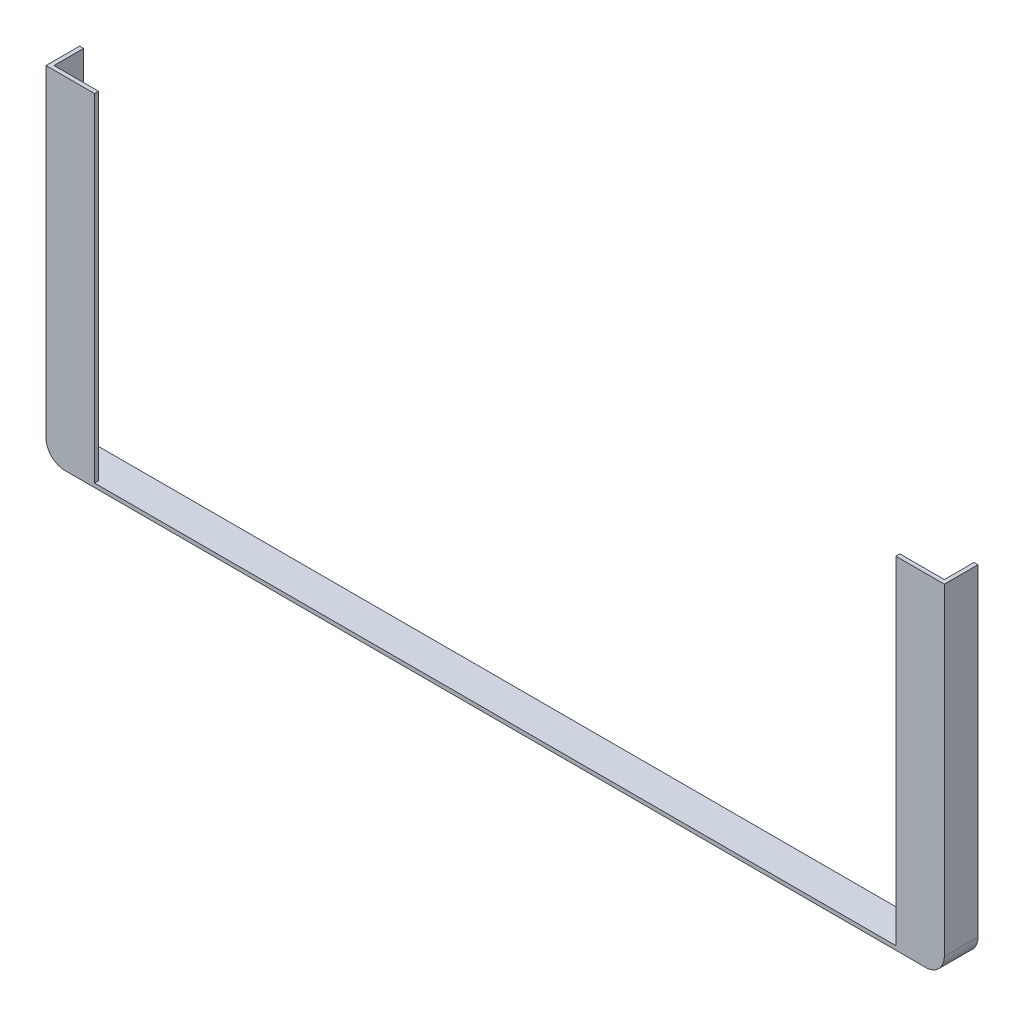
from build123d import *

# Parameters (mm, degrees)
SIDE_DEPTH     = 25.4
PANEL_DEPTH    = 3.4163
BACK_CUT_REACH = 5.416
SKETCH4_W      = 685.8
SKETCH4_H      = 288.6837


with BuildPart() as part:
    # Sketch2 → Side (new body)
    with BuildSketch(Plane.XY):
        with BuildLine():
            Line((-381, 12.7), (-381, 288.6837))
            Line((-381, 288.6837), (-384.4163, 288.6837))
            Line((-384.4163, 288.6837), (-384.4163, 12.7))
            ThreePointArc((-384.4163, 12.7), (-379.695945018, 1.304054982), (-368.3, -3.4163))
            Line((-368.3, -3.4163), (368.3, -3.4163))
            ThreePointArc((368.3, -3.4163), (379.695945018, 1.304054982), (384.4163, 12.7))
            Line((384.4163, 12.7), (384.4163, 288.6837))
            Line((384.4163, 288.6837), (381, 288.6837))
            Line((381, 288.6837), (381, 12.7))
            ThreePointArc((381, 12.7), (377.280256121, 3.719743879), (368.3, 0))
            Line((368.3, 0), (-368.3, 0))
            ThreePointArc((-368.3, 0), (-377.280256121, 3.719743879), (-381, 12.7))
        make_face()
    extrude(amount=-SIDE_DEPTH)

    # Sketch3 → Panel (add)
    with BuildSketch(Plane.XY):
        with BuildLine():
            Line((-368.3, -3.4163), (368.3, -3.4163))
            ThreePointArc((368.3, -3.4163), (379.695945018, 1.304054982), (384.4163, 12.7))
            Line((384.4163, 12.7), (384.4163, 288.6837))
            Line((384.4163, 288.6837), (-384.4163, 288.6837))
            Line((-384.4163, 288.6837), (-384.4163, 12.7))
            ThreePointArc((-384.4163, 12.7), (-379.695945018, 1.304054982), (-368.3, -3.4163))
        make_face()
    extrude(amount=PANEL_DEPTH)

    # Sketch4 → Back Cut (cut, up to next)
    with BuildSketch(Plane(origin=(0, 0, 0), x_dir=(-1, 0, 0), z_dir=(0, 0, -1)), mode=Mode.PRIVATE) as back_cut_sk1:
        with Locations((0, 144.34185)):
            Rectangle(SKETCH4_W, SKETCH4_H)
    back_cut_tool1 = extrude(back_cut_sk1.sketch, amount=-BACK_CUT_REACH, mode=Mode.PRIVATE) & part.part
    add(back_cut_tool1.solids().sort_by_distance((0, 144.34185, 0))[0], mode=Mode.SUBTRACT)


solid = part.part
